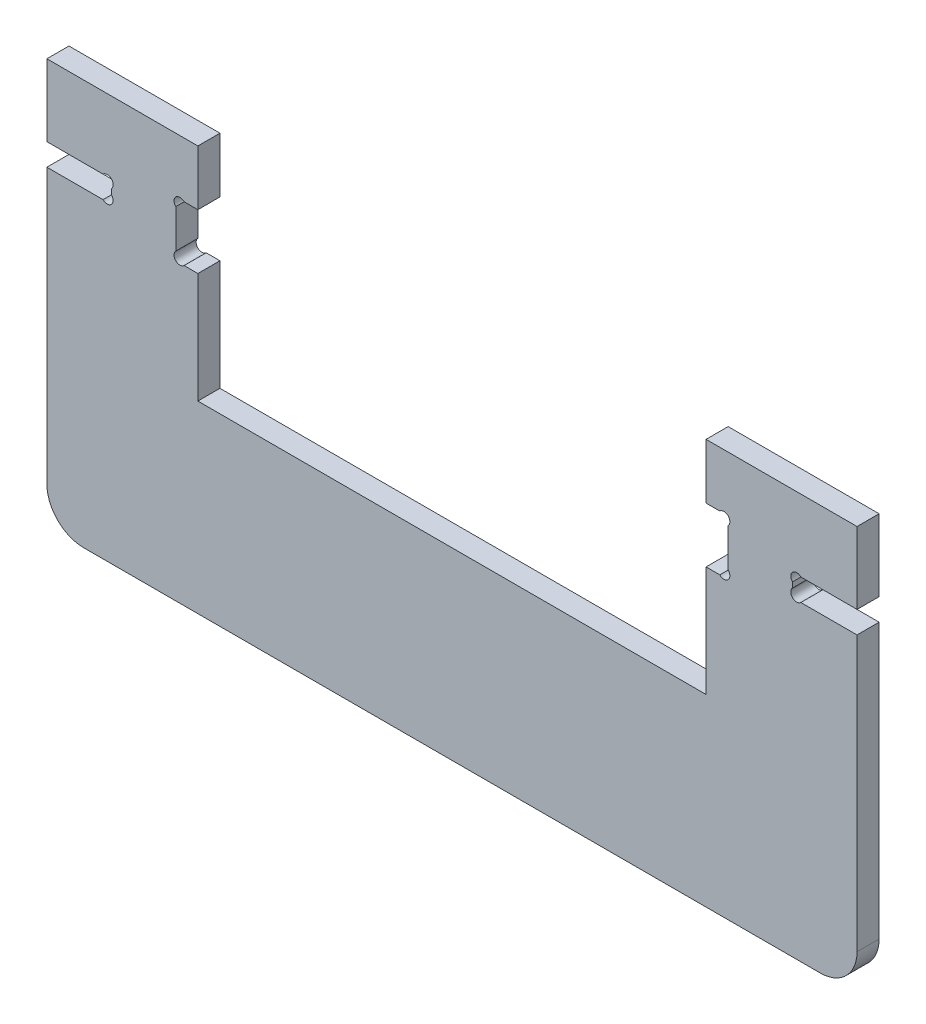
from build123d import *

# Parameters (mm, degrees)
EXTRUSION1_DEPTH = 6


with BuildPart() as part:
    # Esquisse1 → Extrusion1 (new body)
    with BuildSketch(Plane.XY):
        with BuildLine():
            Line((41, 110), (41, 95))
            Line((41, 95), (37.2627417, 95))
            ThreePointArc((37.2627417, 95), (35, 95), (35, 92.7372583))
            Line((35, 92.7372583), (35, 82.2627417))
            ThreePointArc((35, 82.2627417), (35, 80), (37.2627417, 80))
            Line((37.2627417, 80), (41, 80))
            Line((41, 80), (41, 50))
            Line((41, 50), (179, 50))
            Line((179, 50), (179, 80))
            Line((179, 80), (182.7372583, 80))
            ThreePointArc((182.7372583, 80), (185, 80), (185, 82.2627417))
            Line((185, 82.2627417), (185, 92.7372583))
            ThreePointArc((185, 92.7372583), (185, 95), (182.7372583, 95))
            Line((182.7372583, 95), (179, 95))
            Line((179, 95), (179, 110))
            Line((179, 110), (220, 110))
            Line((220, 110), (220, 90.5))
            Line((220, 90.5), (204.7427417, 90.5))
            ThreePointArc((204.7427417, 90.5), (202.48, 90.5), (202.48, 88.2372583))
            Line((202.48, 88.2372583), (202.48, 86.7627417))
            ThreePointArc((202.48, 86.7627417), (202.48, 84.5), (204.7427417, 84.5))
            Line((204.7427417, 84.5), (220, 84.5))
            Line((220, 84.5), (220, 10))
            ThreePointArc((220, 10), (217.071067812, 2.928932188), (210, 0))
            Line((210, 0), (10, 0))
            ThreePointArc((10, 0), (2.928932188, 2.928932188), (0, 10))
            Line((0, 10), (0, 84.5))
            Line((0, 84.5), (15.2572583, 84.5))
            ThreePointArc((15.2572583, 84.5), (17.52, 84.5), (17.52, 86.7627417))
            Line((17.52, 86.7627417), (17.52, 88.2372583))
            ThreePointArc((17.52, 88.2372583), (17.52, 90.5), (15.2572583, 90.5))
            Line((15.2572583, 90.5), (0, 90.5))
            Line((0, 90.5), (0, 110))
            Line((0, 110), (41, 110))
        make_face()
    extrude(amount=EXTRUSION1_DEPTH)


solid = part.part
